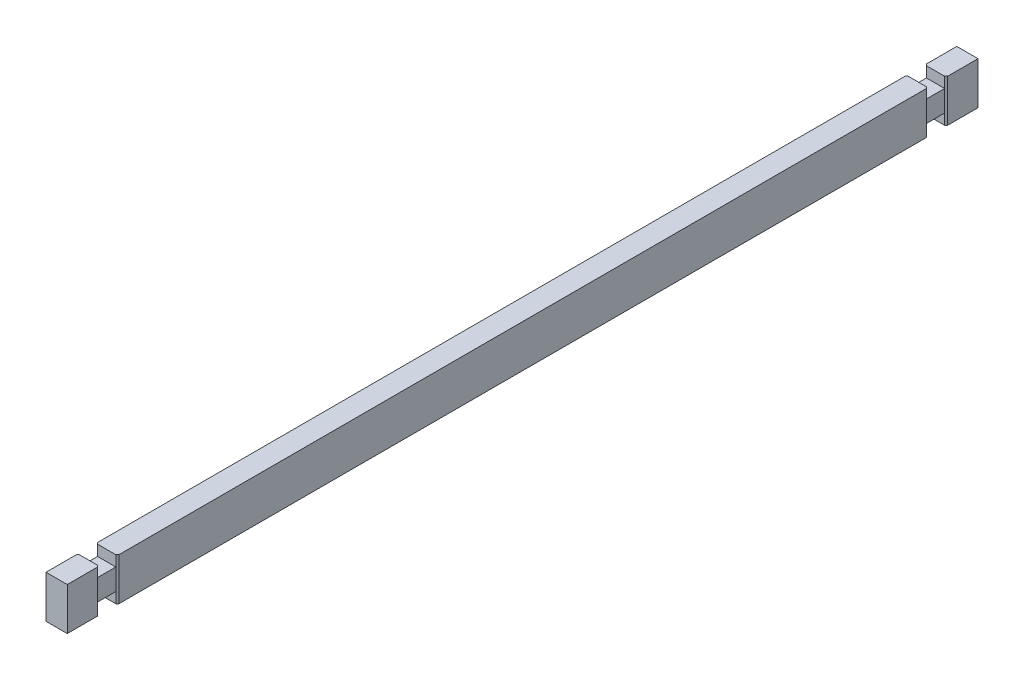
from build123d import *

# Parameters (mm, degrees)
SKETCH1_W          = 70
SKETCH1_H          = 140
EXTRUDE1_DEPTH     = 3000
CUT_EXTRUDE1_DEPTH = 141
SKETCH3_W          = 60
SKETCH3_H          = 35
CUT_EXTRUDE2_DEPTH = 66
CUT_EXTRUDE3_DEPTH = 141
SKETCH5_W          = 60
SKETCH5_H          = 35
CUT_EXTRUDE4_DEPTH = 66


with BuildPart() as part:
    # Sketch1 → Extrude1 (new body)
    with BuildSketch(Plane.XY):
        Rectangle(SKETCH1_W, SKETCH1_H)
    extrude(amount=EXTRUDE1_DEPTH)

    # Sketch2 → Cut-Extrude1 (cut, through all)
    with BuildSketch(Plane(origin=(0, 70, 0), x_dir=(-1, 0, 0), z_dir=(0, 1, 0))):
        Polygon((35, 100), (30, 105), (30, 165), (35, 170), align=None)
        Polygon((-35, 100), (-30, 105), (-30, 165), (-35, 170), align=None)
    extrude(amount=-CUT_EXTRUDE1_DEPTH, mode=Mode.SUBTRACT)

    # Sketch3 → Cut-Extrude2 (cut, through all)
    with BuildSketch(Plane(origin=(30, 0, 0), x_dir=(0, 0, -1), z_dir=(1, 0, 0))):
        with Locations((-135, 52.5)):
            Rectangle(SKETCH3_W, SKETCH3_H)
        with Locations((-135, -52.5)):
            Rectangle(SKETCH3_W, SKETCH3_H)
    extrude(amount=-CUT_EXTRUDE2_DEPTH, mode=Mode.SUBTRACT)

    # Sketch4 → Cut-Extrude3 (cut, through all)
    with BuildSketch(Plane(origin=(0, 70, 0), x_dir=(-1, 0, 0), z_dir=(0, 1, 0))):
        Polygon((-35, 2830), (-35, 2900), (-30, 2894.999998083), (-30, 2834.999998083), align=None)
        Polygon((35, 2830), (30, 2835.000001917), (30, 2895.000001917), (35, 2900), align=None)
    extrude(amount=-CUT_EXTRUDE3_DEPTH, mode=Mode.SUBTRACT)

    # Sketch5 → Cut-Extrude4 (cut, through all)
    with BuildSketch(Plane(origin=(30, 0, 0), x_dir=(0, 0, -1), z_dir=(1, 0, 0))):
        with Locations((-2864.999998083, 52.5)):
            Rectangle(SKETCH5_W, SKETCH5_H)
        with Locations((-2864.999998083, -52.5)):
            Rectangle(SKETCH5_W, SKETCH5_H)
    extrude(amount=-CUT_EXTRUDE4_DEPTH, mode=Mode.SUBTRACT)


solid = part.part
